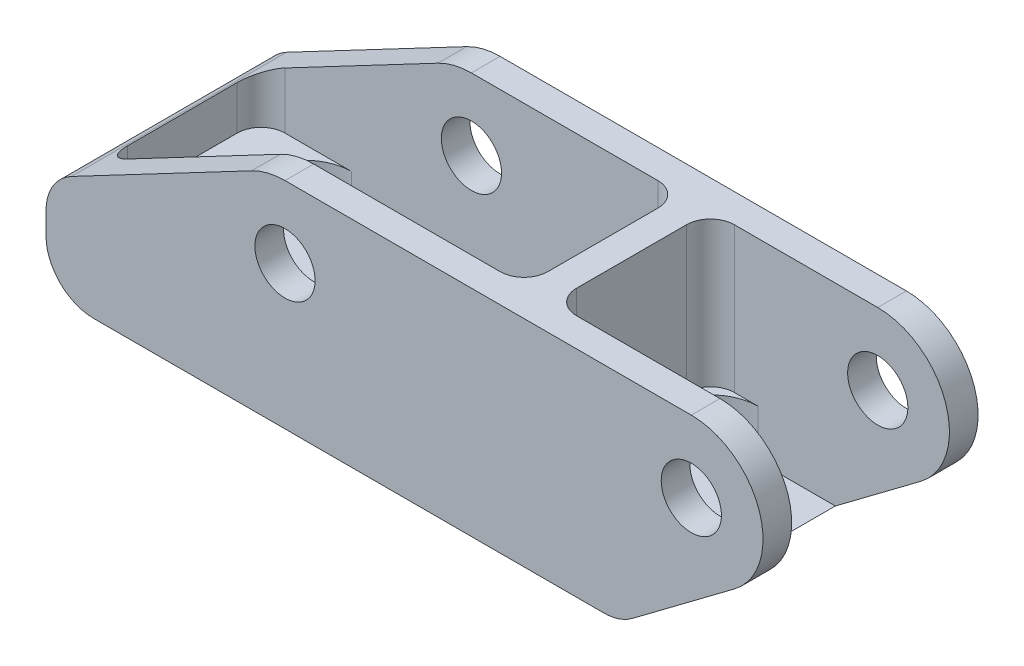
from build123d import *

# Parameters (mm, degrees)
SKETCH1_R           = 3
BOSS_EXTRUDE1_DEPTH = 28.575
CUT_EXTRUDE1_DEPTH  = 19.304
SKETCH9_R           = 3
CUT_EXTRUDE7_DEPTH  = 6.35
SKETCH5_R           = 4
CUT_EXTRUDE3_DEPTH  = 28.575


with BuildPart() as part:
    # Sketch1 → Boss-Extrude1 (new body)
    with BuildSketch(Plane(origin=(0, 0, 0), x_dir=(1, 0, 0), z_dir=(0, 1, 0))):
        Polygon((0, 6.35), (0, 22.225), (0, 28.575), (6.35, 28.575), (88.9, 28.575), (95.25, 28.575), (95.25, 0), (88.9, 0), (6.35, 0), (0, 0), align=None)
        with Locations((12.7, 14.2875)):
            Circle(SKETCH1_R, mode=Mode.SUBTRACT)
        with Locations((50.8, 14.2875)):
            Circle(SKETCH1_R, mode=Mode.SUBTRACT)
    extrude(amount=-BOSS_EXTRUDE1_DEPTH)

    # Sketch2 → Cut-Extrude1 (cut)
    with BuildSketch(Plane(origin=(0, 0, 0), x_dir=(1, 0, 0), z_dir=(0, 1, 0))):
        with BuildLine():
            Line((3.81, 6.985), (3.81, 21.59))
            ThreePointArc((3.81, 21.59), (4.73993597, 23.83506403), (6.985, 24.765))
            Line((6.985, 24.765), (56.515, 24.765))
            ThreePointArc((56.515, 24.765), (58.76006403, 23.83506403), (59.69, 21.59))
            Line((59.69, 21.59), (59.69, 6.985))
            ThreePointArc((59.69, 6.985), (58.76006403, 4.73993597), (56.515, 3.81))
            Line((56.515, 3.81), (6.985, 3.81))
            ThreePointArc((6.985, 3.81), (4.73993597, 4.73993597), (3.81, 6.985))
        make_face()
        with BuildLine():
            Line((63.5, 6.985), (63.5, 21.59))
            ThreePointArc((63.5, 21.59), (64.42993597, 23.83506403), (66.675, 24.765))
            Line((66.675, 24.765), (95.25, 24.765))
            Line((95.25, 24.765), (95.25, 3.81))
            Line((95.25, 3.81), (66.675, 3.81))
            ThreePointArc((66.675, 3.81), (64.42993597, 4.73993597), (63.5, 6.985))
        make_face()
    extrude(amount=-CUT_EXTRUDE1_DEPTH, mode=Mode.SUBTRACT)

    # Sketch9 → Cut-Extrude7 (cut)
    with BuildSketch(Plane(origin=(0, -19.304, 0), x_dir=(1, 0, 0), z_dir=(0, 1, 0))):
        with BuildLine():
            Line((10.793997252, 22.263484848), (7.649092718, 18.135984848))
            ThreePointArc((7.649092718, 18.135984848), (6.35, 14.2875), (7.649092718, 10.439015152))
            Line((7.649092718, 10.439015152), (10.793997252, 6.311515152))
            ThreePointArc((10.793997252, 6.311515152), (13.026694001, 4.469640662), (15.844904534, 3.81))
            Line((15.844904534, 3.81), (47.655095466, 3.81))
            ThreePointArc((47.655095466, 3.81), (50.473305999, 4.469640662), (52.706002748, 6.311515152))
            Line((52.706002748, 6.311515152), (55.850907282, 10.439015152))
            ThreePointArc((55.850907282, 10.439015152), (57.15, 14.2875), (55.850907282, 18.135984848))
            Line((55.850907282, 18.135984848), (52.706002748, 22.263484848))
            ThreePointArc((52.706002748, 22.263484848), (50.473305999, 24.105359338), (47.655095466, 24.765))
            Line((47.655095466, 24.765), (15.844904534, 24.765))
            ThreePointArc((15.844904534, 24.765), (13.026694001, 24.105359338), (10.793997252, 22.263484848))
        make_face()
        with Locations((12.7, 14.2875)):
            Circle(SKETCH9_R, mode=Mode.SUBTRACT)
        with Locations((50.8, 14.2875)):
            Circle(SKETCH9_R, mode=Mode.SUBTRACT)
        with BuildLine():
            ThreePointArc((63.5, 18.415), (65.359871939, 22.905128061), (69.85, 24.765))
            Line((69.85, 24.765), (95.25, 24.765))
            Line((95.25, 24.765), (95.25, 3.81))
            Line((95.25, 3.81), (69.85, 3.81))
            ThreePointArc((69.85, 3.81), (65.359871939, 5.669871939), (63.5, 10.16))
            Line((63.5, 10.16), (63.5, 18.415))
        make_face()
    extrude(amount=-CUT_EXTRUDE7_DEPTH, mode=Mode.SUBTRACT)

    # Sketch5 → Cut-Extrude3 (cut)
    with BuildSketch(Plane(origin=(0, 0, -28.575), x_dir=(-1, 0, 0), z_dir=(0, 0, -1))):
        with BuildLine():
            Line((-95.25, 0), (-95.25, -9.524999828))
            ThreePointArc((-95.25, -9.524999828), (-92.46019203, -2.789807848), (-85.725, 0))
            Line((-85.725, 0), (-95.25, 0))
        make_face()
        with BuildLine():
            Line((-77.893333333, -27.305), (-91.44, -17.145))
            ThreePointArc((-91.44, -17.145), (-94.244419033, -13.78470942), (-95.25, -9.524999828))
            Line((-95.25, -9.524999828), (-95.25, -28.575))
            Line((-95.25, -28.575), (-74.083333333, -28.575))
            ThreePointArc((-74.083333333, -28.575), (-76.091379648, -28.249138943), (-77.893333333, -27.305))
        make_face()
        with BuildLine():
            ThreePointArc((-31.75, 0), (-29.462234044, -0.278825011), (-27.308407483, -1.098975973))
            Line((-27.308407483, -1.098975973), (-3.388938322, -13.707595992))
            ThreePointArc((-3.388938322, -13.707595992), (-0.912848096, -16.044719868), (0, -19.324945344))
            Line((0, -19.324945344), (0, 0))
            Line((0, 0), (-31.75, 0))
        make_face()
        with BuildLine():
            Line((0, -28.575), (0, -22.225))
            ThreePointArc((0, -22.225), (-1.859871939, -26.715128061), (-6.35, -28.575))
            Line((-6.35, -28.575), (0, -28.575))
        make_face()
        with Locations((-31.75, -9.525)):
            Circle(SKETCH5_R)
        with Locations((-85.725, -9.525)):
            Circle(SKETCH5_R)
    extrude(amount=-CUT_EXTRUDE3_DEPTH, mode=Mode.SUBTRACT)


solid = part.part
